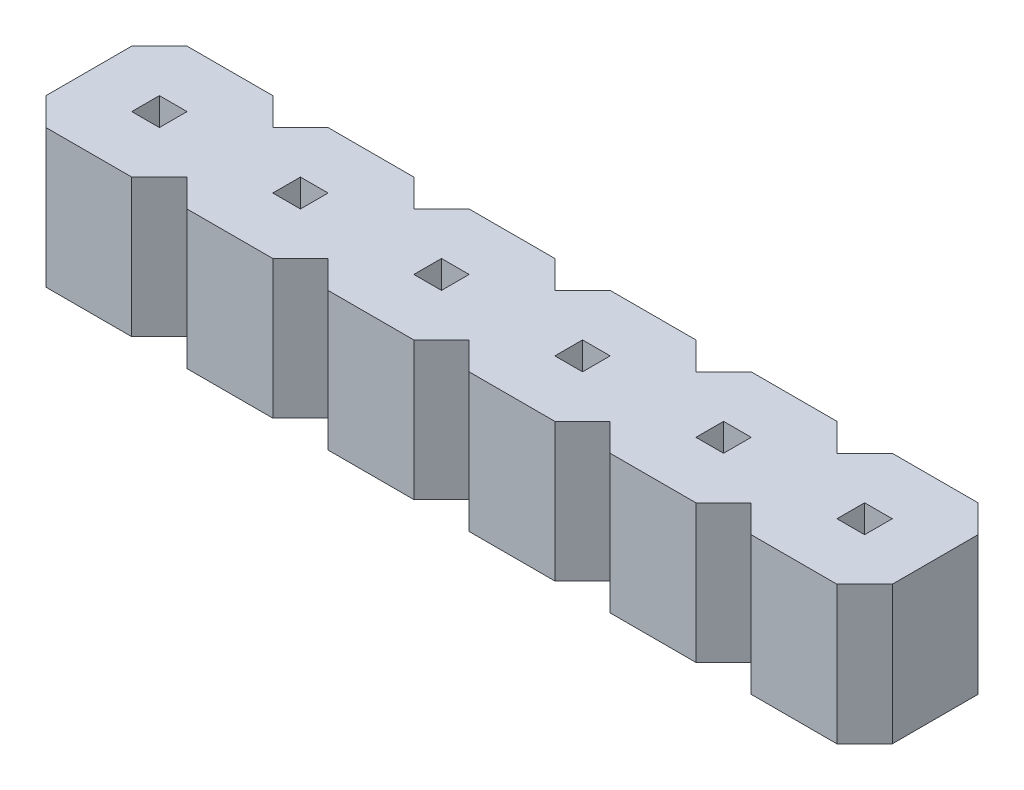
from build123d import *

# Parameters (mm, degrees)
BOSS_EXTRUDE1_DEPTH = 1.25
SKETCH2_W           = 0.5
SKETCH2_H           = 0.5
CUT_EXTRUDE1_DEPTH  = 3.5


with BuildPart() as part:
    # Sketch1 → Boss-Extrude1 (new body, symmetric)
    with BuildSketch(Plane(origin=(0, 0, 0), x_dir=(1, 0, 0), z_dir=(0, 1, 0))):
        Polygon((-0.775, 1.275), (-1.275, 0.775), (-1.275, -0.775), (-0.775, -1.275), (0.775, -1.275), (1.275, -0.775), (1.775, -1.275), (3.325, -1.275), (3.825, -0.775), (4.325, -1.275), (5.875, -1.275), (6.375, -0.775), (6.875, -1.275), (8.425, -1.275), (8.925, -0.775), (9.425, -1.275), (10.975, -1.275), (11.475, -0.775), (11.975, -1.275), (13.525, -1.275), (14.025, -0.775), (14.025, 0.775), (13.525, 1.275), (11.975, 1.275), (11.475, 0.775), (10.975, 1.275), (9.425, 1.275), (8.925, 0.775), (8.425, 1.275), (6.875, 1.275), (6.375, 0.775), (5.875, 1.275), (4.325, 1.275), (3.825, 0.775), (3.325, 1.275), (1.775, 1.275), (1.275, 0.775), (0.775, 1.275), align=None)
    extrude(amount=BOSS_EXTRUDE1_DEPTH, both=True)

    # Sketch2 → Cut-Extrude1 (cut, through all)
    with BuildSketch(Plane(origin=(0, 1.25, 0), x_dir=(1, 0, 0), z_dir=(0, 1, 0))):
        with Locations((2.55, 0)):
            Rectangle(SKETCH2_W, SKETCH2_H)
        Rectangle(SKETCH2_W, SKETCH2_H)
        with Locations((5.1, 0)):
            Rectangle(SKETCH2_W, SKETCH2_H)
        with Locations((7.65, 0)):
            Rectangle(SKETCH2_W, SKETCH2_H)
        with Locations((10.2, 0)):
            Rectangle(SKETCH2_W, SKETCH2_H)
        with Locations((12.75, 0)):
            Rectangle(SKETCH2_W, SKETCH2_H)
    extrude(amount=-CUT_EXTRUDE1_DEPTH, mode=Mode.SUBTRACT)


solid = part.part
